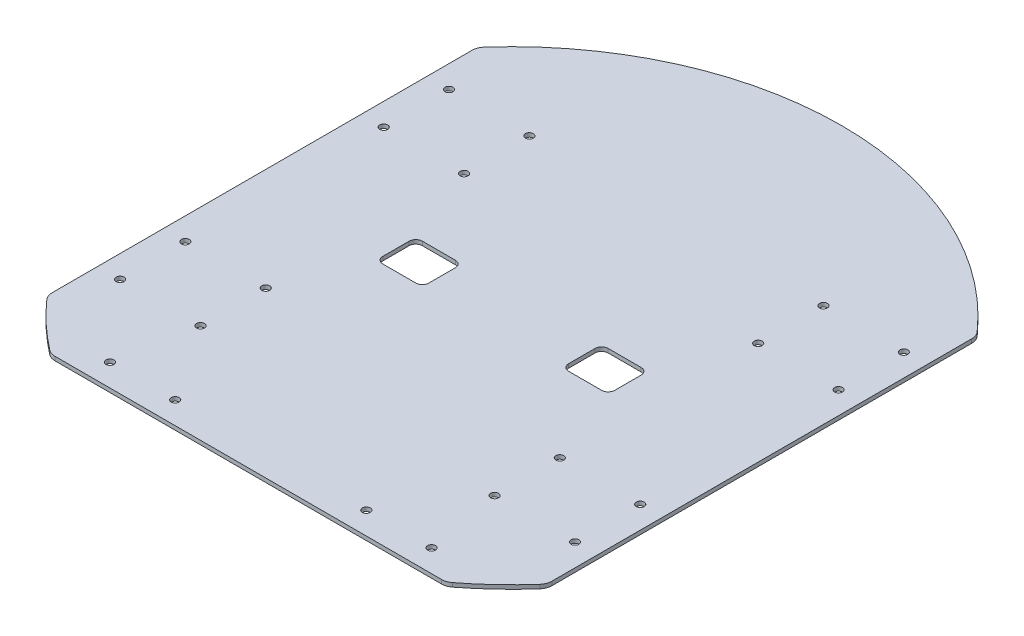
from build123d import *

# Parameters (mm, degrees)
BOSS_EXTRUDE1_DEPTH     = 3
FILLET1_R               = 10
SKETCH2_R               = 3
CUT_EXTRUDE1_DEPTH      = 1
CUT_EXTRUDE1_DEPTH_BACK = 4


with BuildPart() as part:
    # Sketch1 → Boss-Extrude1 (new body)
    with BuildSketch(Plane(origin=(0, 0, 0), x_dir=(1, 0, 0), z_dir=(0, 1, 0))):
        with BuildLine():
            Line((-189.549594269, 163.005985511), (-189.549594269, 15))
            Line((-189.549594269, 15), (-189.549594269, -15))
            Line((-189.549594269, -15), (-189.549594269, -163.005985511))
            ThreePointArc((-189.549594269, -163.005985511), (-170.779451396, -182.577049436), (-150, -200))
            Line((-150, -200), (150, -200))
            ThreePointArc((150, -200), (170.779451396, -182.577049436), (189.549594269, -163.005985511))
            Line((189.549594269, -163.005985511), (189.549594269, -15))
            Line((189.549594269, -15), (189.549594269, 15))
            Line((189.549594269, 15), (189.549594269, 163.005985511))
            ThreePointArc((189.549594269, 163.005985511), (0, 250), (-189.549594269, 163.005985511))
        make_face()
        with BuildLine():
            ThreePointArc((-83, -15), (-86.535533906, -13.535533906), (-88, -10))
            Line((-88, -10), (-88, 10))
            ThreePointArc((-88, 10), (-86.535533906, 13.535533906), (-83, 15))
            Line((-83, 15), (-58, 15))
            ThreePointArc((-58, 15), (-54.464466094, 13.535533906), (-53, 10))
            Line((-53, 10), (-53, -10))
            ThreePointArc((-53, -10), (-54.464466094, -13.535533906), (-58, -15))
            Line((-58, -15), (-83, -15))
        make_face(mode=Mode.SUBTRACT)
        with BuildLine():
            Line((53, -10), (53, 10))
            ThreePointArc((53, 10), (54.464466094, 13.535533906), (58, 15))
            Line((58, 15), (83, 15))
            ThreePointArc((83, 15), (86.535533906, 13.535533906), (88, 10))
            Line((88, 10), (88, -10))
            ThreePointArc((88, -10), (86.535533906, -13.535533906), (83, -15))
            Line((83, -15), (58, -15))
            ThreePointArc((58, -15), (54.464466094, -13.535533906), (53, -10))
        make_face(mode=Mode.SUBTRACT)
    extrude(amount=BOSS_EXTRUDE1_DEPTH)

    # Fillet1
    fillet1_edges = [part.edges().sort_by_distance(p)[0] for p in [
        (189.549594269, 1.5, 163.005985511),
        (150, 1.5, 200),
        (-150, 1.5, 200),
        (-189.549594269, 1.5, 163.005985511),
        (-189.549594269, 1.5, -163.005985511),
        (189.549594269, 1.5, -163.005985511),
    ]]
    fillet(fillet1_edges, radius=FILLET1_R)

    # Sketch2 → Cut-Extrude1 (cut, two sides)
    with BuildSketch(Plane.XZ) as cut_extrude1_sk:
        with Locations((-172.549594269, -124.75)):
            Circle(SKETCH2_R)
        with Locations((-172.549594269, -75.25)):
            Circle(SKETCH2_R)
        with Locations((-111.549594269, -124.75)):
            Circle(SKETCH2_R)
        with Locations((-111.549594269, -75.25)):
            Circle(SKETCH2_R)
        with Locations((111.549594269, -75.25)):
            Circle(SKETCH2_R)
        with Locations((172.549594269, -75.25)):
            Circle(SKETCH2_R)
        with Locations((172.549594269, -124.75)):
            Circle(SKETCH2_R)
        with Locations((111.549594269, -124.75)):
            Circle(SKETCH2_R)
        with Locations((172.549594269, 75.25)):
            Circle(SKETCH2_R)
        with Locations((172.549594269, 124.75)):
            Circle(SKETCH2_R)
        with Locations((111.549594269, 124.75)):
            Circle(SKETCH2_R)
        with Locations((111.549594269, 75.25)):
            Circle(SKETCH2_R)
        with Locations((-172.549594269, 75.25)):
            Circle(SKETCH2_R)
        with Locations((-111.549594269, 75.25)):
            Circle(SKETCH2_R)
        with Locations((-111.549594269, 124.75)):
            Circle(SKETCH2_R)
        with Locations((-172.549594269, 124.75)):
            Circle(SKETCH2_R)
        with Locations((-122, 183)):
            Circle(SKETCH2_R)
        with Locations((-72.5, 183)):
            Circle(SKETCH2_R)
        with Locations((72.5, 183)):
            Circle(SKETCH2_R)
        with Locations((122, 183)):
            Circle(SKETCH2_R)
    extrude(amount=CUT_EXTRUDE1_DEPTH, mode=Mode.SUBTRACT)
    extrude(cut_extrude1_sk.sketch, amount=-CUT_EXTRUDE1_DEPTH_BACK, mode=Mode.SUBTRACT)


solid = part.part
